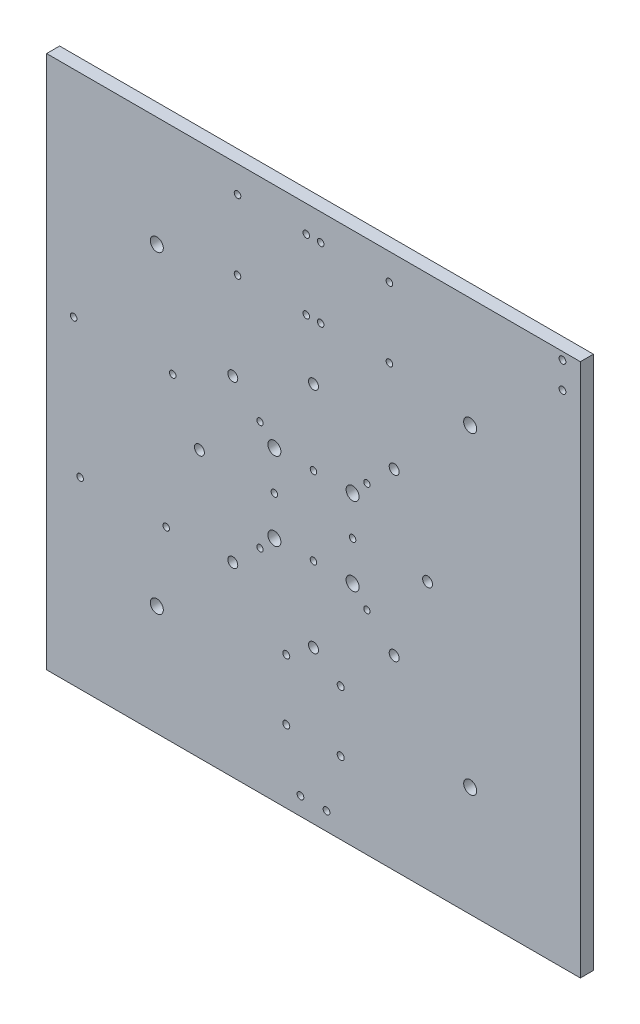
from build123d import *

# Parameters (mm, degrees)
SKETCH1_W           = 260
SKETCH1_H           = 260
SKETCH1_R           = 1.55
SKETCH1_R_2         = 1.5875
SKETCH1_R_3         = 1.6
SKETCH1_R_4         = 1.7
SKETCH1_R_5         = 3.175
SKETCH1_R_6         = 2.415
SKETCH1_R_7         = 1.651
BOSS_EXTRUDE2_DEPTH = 6.35
SKETCH2_R           = 1.5875
CUT_EXTRUDE1_DEPTH  = 7.35
SKETCH3_R           = 3.175
CUT_EXTRUDE2_DEPTH  = 7.35


with BuildPart() as part:
    # Sketch1 → Boss-Extrude2 (new body)
    with BuildSketch(Plane.XY):
        Rectangle(SKETCH1_W, SKETCH1_H)
        with Locations((-26.035, 26.67)):
            Circle(SKETCH1_R, mode=Mode.SUBTRACT)
        with Locations((-26.035, -26.67)):
            Circle(SKETCH1_R, mode=Mode.SUBTRACT)
        with Locations((26.035, 26.67)):
            Circle(SKETCH1_R, mode=Mode.SUBTRACT)
        with Locations((26.035, -26.67)):
            Circle(SKETCH1_R, mode=Mode.SUBTRACT)
        with Locations((-116.825, 25.402702903)):
            Circle(SKETCH1_R_2, mode=Mode.SUBTRACT)
        with Locations((-113.65, -40.635194695)):
            Circle(SKETCH1_R_2, mode=Mode.SUBTRACT)
        with Locations((-68.565, 25.404805305)):
            Circle(SKETCH1_R_2, mode=Mode.SUBTRACT)
        with Locations((-37, 117)):
            Circle(SKETCH1_R_3, mode=Mode.SUBTRACT)
        with Locations((-37, 83)):
            Circle(SKETCH1_R_3, mode=Mode.SUBTRACT)
        with Locations((-3.5, 117)):
            Circle(SKETCH1_R_3, mode=Mode.SUBTRACT)
        with Locations((-3.5, 83)):
            Circle(SKETCH1_R_3, mode=Mode.SUBTRACT)
        with Locations((3.5, 117)):
            Circle(SKETCH1_R_3, mode=Mode.SUBTRACT)
        with Locations((37, 117)):
            Circle(SKETCH1_R_3, mode=Mode.SUBTRACT)
        with Locations((37, 83)):
            Circle(SKETCH1_R_3, mode=Mode.SUBTRACT)
        with Locations((3.5, 83)):
            Circle(SKETCH1_R_3, mode=Mode.SUBTRACT)
        with Locations((-13.25, -65.25)):
            Circle(SKETCH1_R_4, mode=Mode.SUBTRACT)
        with Locations((13.25, -65.25)):
            Circle(SKETCH1_R_4, mode=Mode.SUBTRACT)
        with Locations((13.25, -94.75)):
            Circle(SKETCH1_R_4, mode=Mode.SUBTRACT)
        with Locations((-13.25, -94.75)):
            Circle(SKETCH1_R_4, mode=Mode.SUBTRACT)
        with Locations((-76.33, 76.33)):
            Circle(SKETCH1_R_5, mode=Mode.SUBTRACT)
        with Locations((0, 55.575)):
            Circle(SKETCH1_R_6, mode=Mode.SUBTRACT)
        with Locations((-55.575, 0)):
            Circle(SKETCH1_R_6, mode=Mode.SUBTRACT)
        with Locations((0, -55.575)):
            Circle(SKETCH1_R_6, mode=Mode.SUBTRACT)
        with Locations((55.575, 0)):
            Circle(SKETCH1_R_6, mode=Mode.SUBTRACT)
        with Locations((-39.297459364, 39.297459364)):
            Circle(SKETCH1_R_6, mode=Mode.SUBTRACT)
        with Locations((39.297459364, 39.297459364)):
            Circle(SKETCH1_R_6, mode=Mode.SUBTRACT)
        with Locations((39.297459364, -39.297459364)):
            Circle(SKETCH1_R_6, mode=Mode.SUBTRACT)
        with Locations((-39.297459364, -39.297459364)):
            Circle(SKETCH1_R_6, mode=Mode.SUBTRACT)
        with Locations((76.33, 76.33)):
            Circle(SKETCH1_R_5, mode=Mode.SUBTRACT)
        with Locations((76.33, -76.33)):
            Circle(SKETCH1_R_5, mode=Mode.SUBTRACT)
        with Locations((-76.33, -76.33)):
            Circle(SKETCH1_R_5, mode=Mode.SUBTRACT)
        with Locations((-71.74, -40.635194695)):
            Circle(SKETCH1_R_2, mode=Mode.SUBTRACT)
        with Locations((6.35, -121.3)):
            Circle(SKETCH1_R_7, mode=Mode.SUBTRACT)
        with Locations((-6.35, -121.3)):
            Circle(SKETCH1_R_7, mode=Mode.SUBTRACT)
        with Locations((121.3, 126.35)):
            Circle(SKETCH1_R_7, mode=Mode.SUBTRACT)
        with Locations((121.3, 113.65)):
            Circle(SKETCH1_R_7, mode=Mode.SUBTRACT)
    extrude(amount=BOSS_EXTRUDE2_DEPTH)

    # Sketch2 → Cut-Extrude1 (cut, through all)
    with BuildSketch(Plane(origin=(0, 0, 0), x_dir=(-1, 0, 0), z_dir=(0, 0, -1))):
        with Locations((0, 19.05)):
            Circle(SKETCH2_R)
        with Locations((-19.05, 0)):
            Circle(SKETCH2_R)
        with Locations((19.05, 0)):
            Circle(SKETCH2_R)
        with Locations((0, -19.05)):
            Circle(SKETCH2_R)
    extrude(amount=-CUT_EXTRUDE1_DEPTH, mode=Mode.SUBTRACT)

    # Sketch3 → Cut-Extrude2 (cut, through all)
    with BuildSketch(Plane(origin=(0, 0, 0), x_dir=(-1, 0, 0), z_dir=(0, 0, -1))):
        with Locations((-19.05, 19.05)):
            Circle(SKETCH3_R)
        with Locations((19.05, 19.05)):
            Circle(SKETCH3_R)
        with Locations((-19.05, -19.05)):
            Circle(SKETCH3_R)
        with Locations((19.05, -19.05)):
            Circle(SKETCH3_R)
    extrude(amount=-CUT_EXTRUDE2_DEPTH, mode=Mode.SUBTRACT)


solid = part.part
